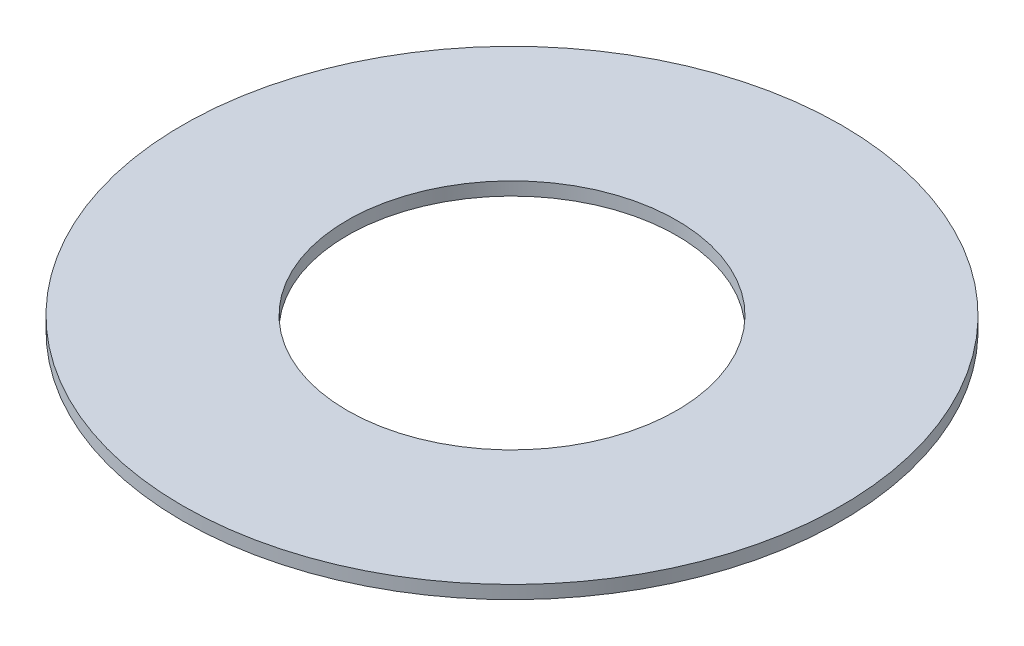
from build123d import *

# Parameters (mm, degrees)
SKETCH1_R           = 5
BOSS_EXTRUDE1_DEPTH = 0.2
SKETCH5_R           = 2.5
CUT_EXTRUDE1_DEPTH  = 1.2


with BuildPart() as part:
    # Sketch1 → Boss-Extrude1 (new body)
    with BuildSketch(Plane(origin=(0, 0, 0), x_dir=(1, 0, 0), z_dir=(0, 1, 0))):
        Circle(SKETCH1_R)
    extrude(amount=BOSS_EXTRUDE1_DEPTH)

    # Sketch5 → Cut-Extrude1 (cut, through all)
    with BuildSketch(Plane(origin=(0, 0.2, 0), x_dir=(-1, 0, 0), z_dir=(0, 1, 0))):
        Circle(SKETCH5_R)
    extrude(amount=-CUT_EXTRUDE1_DEPTH, mode=Mode.SUBTRACT)


solid = part.part
